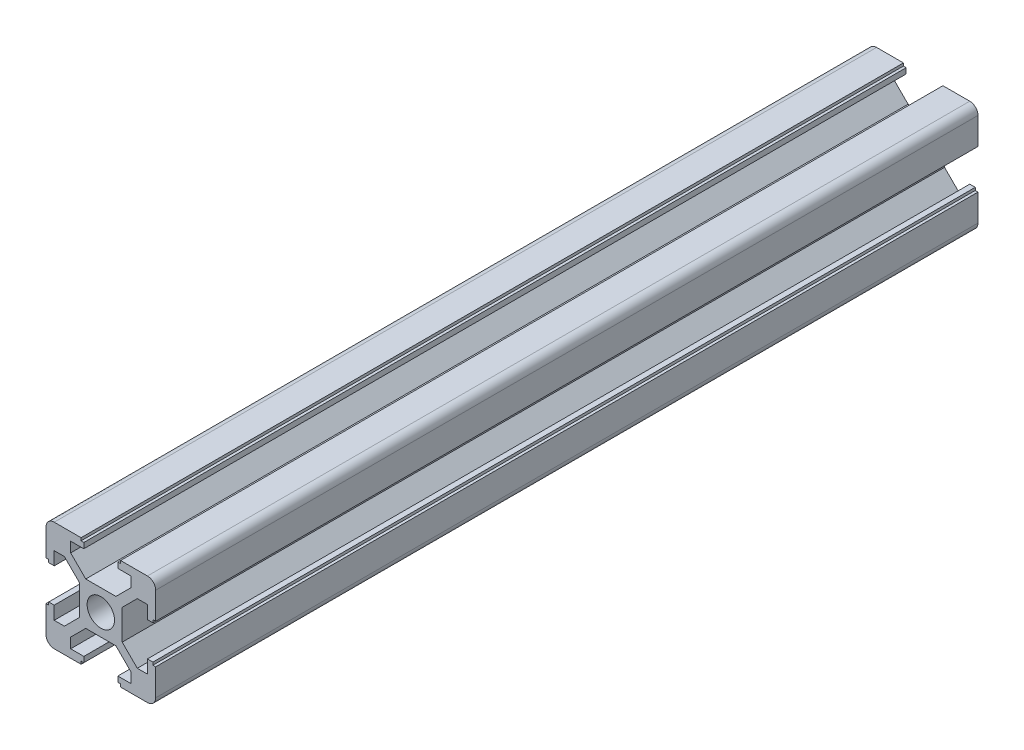
from build123d import *

# Parameters (mm, degrees)
SKETCH_1_R      = 2.5
EXTRUDE_1_DEPTH = 150


with BuildPart() as part:
    # 草图1 → 凸台-拉伸1 (new body)
    with BuildSketch(Plane.XY):
        with BuildLine():
            Line((-3.6, 10), (-3.6, 9.5))
            Line((-3.6, 9.5), (-3.1, 9.5))
            Line((-3.1, 9.5), (-3.1, 8.5))
            Line((-3.1, 8.5), (-5.5, 8.5))
            Line((-5.5, 8.5), (-5.5, 6.65))
            Line((-5.5, 6.65), (-2.75, 3.9))
            Line((-2.75, 3.9), (2.75, 3.9))
            Line((2.75, 3.9), (5.5, 6.65))
            Line((5.5, 6.65), (5.5, 8.5))
            Line((5.5, 8.5), (3.1, 8.5))
            Line((3.1, 8.5), (3.1, 9.5))
            Line((3.1, 9.5), (3.6, 9.5))
            Line((3.6, 9.5), (3.6, 10))
            Line((3.6, 10), (8.5, 10))
            ThreePointArc((8.5, 10), (9.560660172, 9.560660172), (10, 8.5))
            Line((10, 8.5), (10, 3.6))
            Line((10, 3.6), (9.5, 3.6))
            Line((9.5, 3.6), (9.5, 3.1))
            Line((9.5, 3.1), (8.5, 3.1))
            Line((8.5, 3.1), (8.5, 5.5))
            Line((8.5, 5.5), (6.65, 5.5))
            Line((6.65, 5.5), (3.9, 2.75))
            Line((3.9, 2.75), (3.9, -2.75))
            Line((3.9, -2.75), (6.65, -5.5))
            Line((6.65, -5.5), (8.5, -5.5))
            Line((8.5, -5.5), (8.5, -3.1))
            Line((8.5, -3.1), (9.5, -3.1))
            Line((9.5, -3.1), (9.5, -3.6))
            Line((9.5, -3.6), (10, -3.6))
            Line((10, -3.6), (10, -8.5))
            ThreePointArc((10, -8.5), (9.560660172, -9.560660172), (8.5, -10))
            Line((8.5, -10), (3.6, -10))
            Line((3.6, -10), (3.6, -9.5))
            Line((3.6, -9.5), (3.1, -9.5))
            Line((3.1, -9.5), (3.1, -8.5))
            Line((3.1, -8.5), (5.5, -8.5))
            Line((5.5, -8.5), (5.5, -6.65))
            Line((5.5, -6.65), (2.75, -3.9))
            Line((2.75, -3.9), (-2.75, -3.9))
            Line((-2.75, -3.9), (-5.5, -6.65))
            Line((-5.5, -6.65), (-5.5, -8.5))
            Line((-5.5, -8.5), (-3.1, -8.5))
            Line((-3.1, -8.5), (-3.1, -9.5))
            Line((-3.1, -9.5), (-3.6, -9.5))
            Line((-3.6, -9.5), (-3.6, -10))
            Line((-3.6, -10), (-8.5, -10))
            ThreePointArc((-8.5, -10), (-9.560660172, -9.560660172), (-10, -8.5))
            Line((-10, -8.5), (-10, -3.6))
            Line((-10, -3.6), (-9.5, -3.6))
            Line((-9.5, -3.6), (-9.5, -3.1))
            Line((-9.5, -3.1), (-8.5, -3.1))
            Line((-8.5, -3.1), (-8.5, -5.5))
            Line((-8.5, -5.5), (-6.65, -5.5))
            Line((-6.65, -5.5), (-3.9, -2.75))
            Line((-3.9, -2.75), (-3.9, 2.75))
            Line((-3.9, 2.75), (-6.65, 5.5))
            Line((-6.65, 5.5), (-8.5, 5.5))
            Line((-8.5, 5.5), (-8.5, 3.1))
            Line((-8.5, 3.1), (-9.5, 3.1))
            Line((-9.5, 3.1), (-9.5, 3.6))
            Line((-9.5, 3.6), (-10, 3.6))
            Line((-10, 3.6), (-10, 8.5))
            ThreePointArc((-10, 8.5), (-9.560660172, 9.560660172), (-8.5, 10))
            Line((-8.5, 10), (-3.6, 10))
        make_face()
        Circle(SKETCH_1_R, mode=Mode.SUBTRACT)
    extrude(amount=EXTRUDE_1_DEPTH)


solid = part.part
